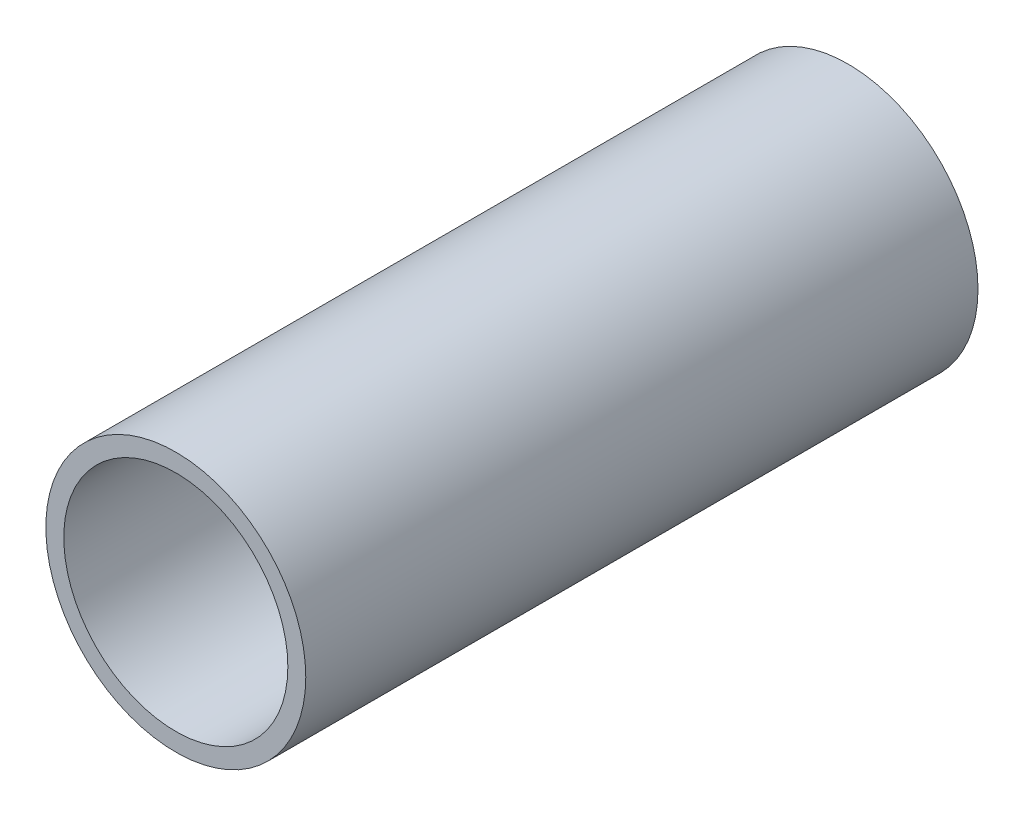
from build123d import *

# Parameters (mm, degrees)
SKETCH1_R           = 14.5
SKETCH1_R_2         = 9.85
BOSS_EXTRUDE1_DEPTH = 9
SKETCH2_R           = 14.5
SKETCH2_R_2         = 12.5
BOSS_EXTRUDE2_DEPTH = 37.5


with BuildPart() as part:
    # Sketch1 → Boss-Extrude1 (new body, symmetric)
    with BuildSketch(Plane.XY):
        Circle(SKETCH1_R)
        Circle(SKETCH1_R_2, mode=Mode.SUBTRACT)
    extrude(amount=BOSS_EXTRUDE1_DEPTH, both=True)

    # Sketch2 → Boss-Extrude2 (add, symmetric)
    with BuildSketch(Plane.XY):
        Circle(SKETCH2_R)
        Circle(SKETCH2_R_2, mode=Mode.SUBTRACT)
    extrude(amount=BOSS_EXTRUDE2_DEPTH, both=True)


solid = part.part
